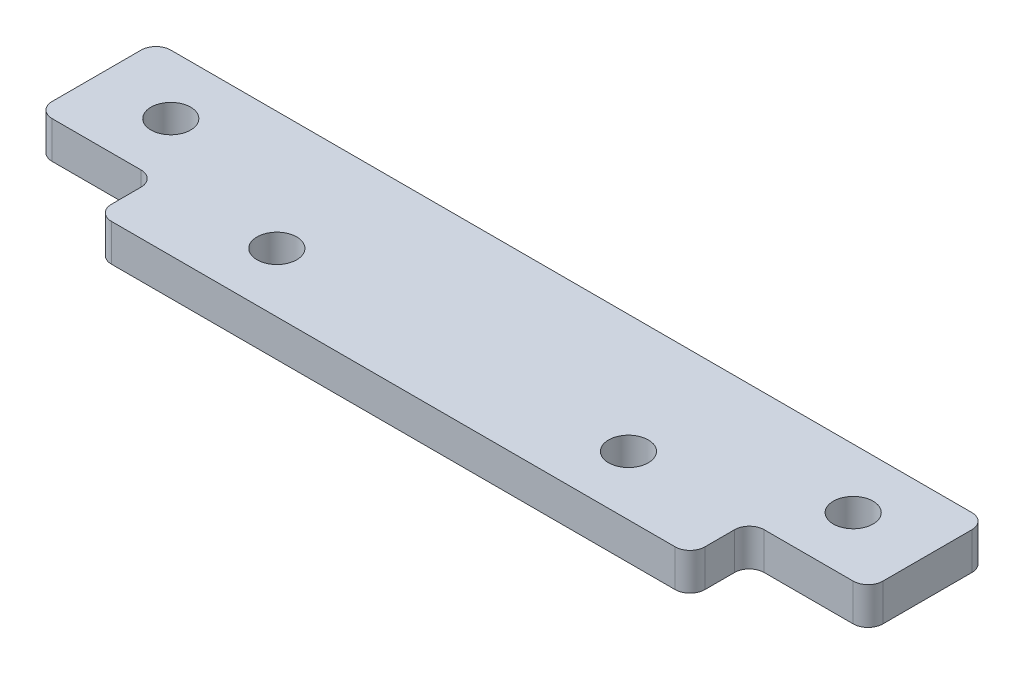
from build123d import *

# Parameters (mm, degrees)
BOSS_EXTRUDE1_DEPTH  = 3.175
M3_CLEARANCE_HOLE2_D = 3.4
FILLET1_R            = 1.27


with BuildPart() as part:
    # Sketch1 → Boss-Extrude1 (new body)
    with BuildSketch(Plane(origin=(0, 0, 0), x_dir=(1, 0, 0), z_dir=(0, 1, 0))):
        Polygon((0, 0), (50.8, 0), (50.8, 5.08), (60.96, 5.08), (60.96, 15.24), (-10.16, 15.24), (-10.16, 5.08), (0, 5.08), align=None)
    extrude(amount=BOSS_EXTRUDE1_DEPTH)

    # M3 Clearance Hole2 (through all)
    with Locations(Plane(origin=(0, 3.175, 0), x_dir=(1, 0, 0), z_dir=(0, 1, 0))):
        with Locations((-3.81, 10.16), (10.3505, 5.08), (40.4495, 5.08), (54.61, 10.16)):
            Hole(M3_CLEARANCE_HOLE2_D / 2)

    # Fillet1
    fillet1_edges = [part.edges().sort_by_distance(p)[0] for p in [
        (0, 1.5875, -5.08),
        (-10.16, 1.5875, -5.08),
        (-10.16, 1.5875, -15.24),
        (60.96, 1.5875, -15.24),
        (60.96, 1.5875, -5.08),
        (50.8, 1.5875, -5.08),
        (50.8, 1.5875, 0),
        (0, 1.5875, 0),
    ]]
    fillet(fillet1_edges, radius=FILLET1_R)


solid = part.part
